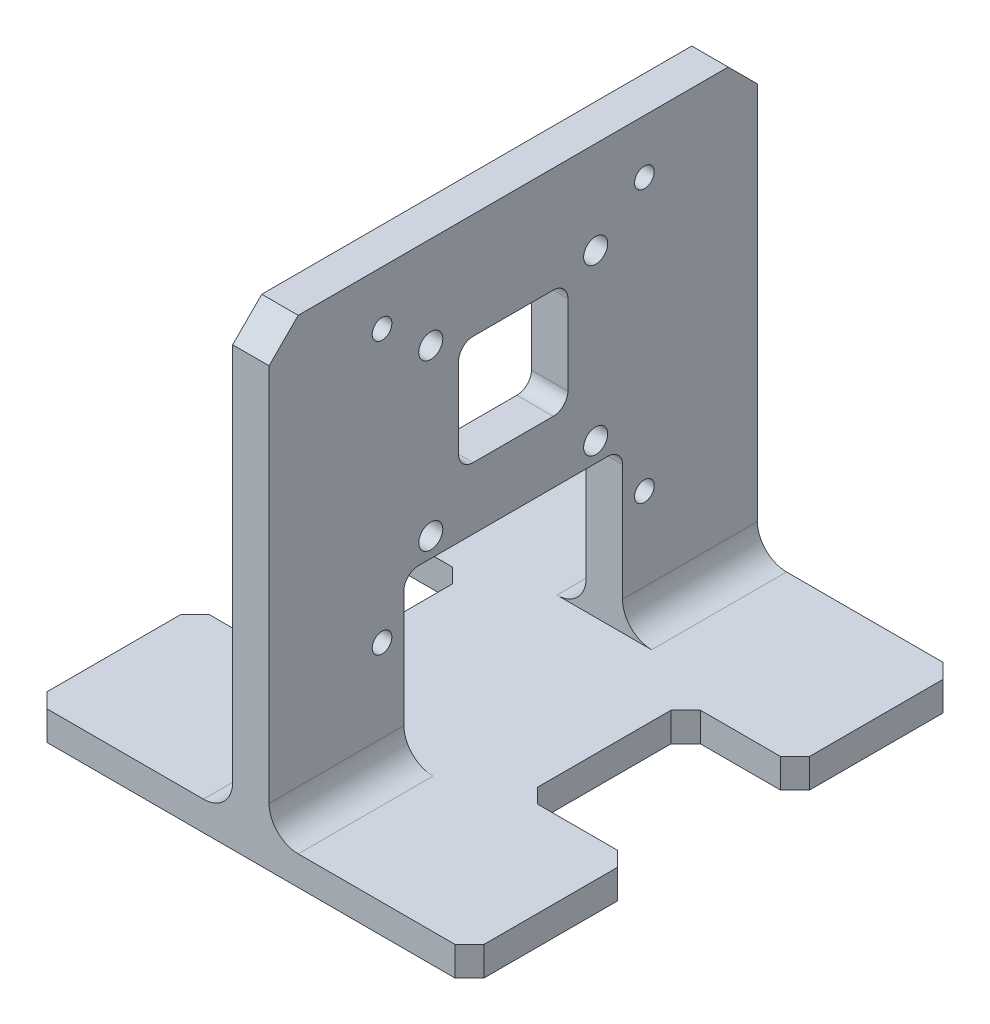
from build123d import *

# Parameters (mm, degrees)
BOSS_EXTRUDE1_DEPTH = 4
SKETCH2_W           = 5
SKETCH2_H           = 67
BOSS_EXTRUDE2_DEPTH = 60
SKETCH3_R           = 1.65
CUT_EXTRUDE1_DEPTH  = 33.5
SKETCH6_R           = 1.35
CUT_EXTRUDE3_DEPTH  = 33.5
SKETCH8_W           = 15
SKETCH8_H           = 15
CUT_EXTRUDE4_DEPTH  = 33.5
SKETCH9_W           = 30
SKETCH9_H           = 22
CUT_EXTRUDE5_DEPTH  = 33.5
FILLET1_R           = 2
FILLET2_R           = 2
CHAMFER1_SIZE       = 2
CHAMFER2_SIZE       = 2
CHAMFER3_SIZE       = 4
FILLET4_R           = 4


with BuildPart() as part:
    # Sketch1 → Boss-Extrude1 (new body)
    with BuildSketch(Plane(origin=(0, 0, 0), x_dir=(1, 0, 0), z_dir=(0, 1, 0))):
        Polygon((-30, 33.5), (30, 33.5), (30, 11.166666667), (15, 11.166666667), (15, -11.166666667), (30, -11.166666667), (30, -33.5), (-30, -33.5), (-30, -11.166666667), (-15, -11.166666667), (-15, 11.166666667), (-30, 11.166666667), align=None)
    extrude(amount=BOSS_EXTRUDE1_DEPTH)

    # Sketch2 → Boss-Extrude2 (add)
    with BuildSketch(Plane(origin=(0, 4, 0), x_dir=(1, 0, 0), z_dir=(0, 1, 0))):
        Rectangle(SKETCH2_W, SKETCH2_H)
    extrude(amount=BOSS_EXTRUDE2_DEPTH)

    # Sketch3 → Cut-Extrude1 (cut, through all)
    with BuildSketch(Plane.ZY.offset(2.5)):
        with Locations((-11.315, 51.315)):
            Circle(SKETCH3_R)
        with Locations((-11.315, 28.685)):
            Circle(SKETCH3_R)
        with Locations((11.315, 28.685)):
            Circle(SKETCH3_R)
        with Locations((11.315, 51.315)):
            Circle(SKETCH3_R)
    extrude(amount=-CUT_EXTRUDE1_DEPTH, mode=Mode.SUBTRACT)

    # Sketch6 → Cut-Extrude3 (cut, through all)
    with BuildSketch(Plane.ZY.offset(2.5)):
        with Locations((-18, 56.64)):
            Circle(SKETCH6_R)
        with Locations((18, 56.64)):
            Circle(SKETCH6_R)
        with Locations((18, 19.36)):
            Circle(SKETCH6_R)
        with Locations((-18, 19.36)):
            Circle(SKETCH6_R)
    extrude(amount=-CUT_EXTRUDE3_DEPTH, mode=Mode.SUBTRACT)

    # Sketch8 → Cut-Extrude4 (cut, through all)
    with BuildSketch(Plane(origin=(2.5, 0, 0), x_dir=(0, 0, -1), z_dir=(1, 0, 0))):
        with Locations((0, 42)):
            Rectangle(SKETCH8_W, SKETCH8_H)
    extrude(amount=-CUT_EXTRUDE4_DEPTH, mode=Mode.SUBTRACT)

    # Sketch9 → Cut-Extrude5 (cut, through all)
    with BuildSketch(Plane(origin=(2.5, 0, 0), x_dir=(0, 0, -1), z_dir=(1, 0, 0))):
        with Locations((0, 15)):
            Rectangle(SKETCH9_W, SKETCH9_H)
    extrude(amount=-CUT_EXTRUDE5_DEPTH, mode=Mode.SUBTRACT)

    # Fillet1
    fillet1_edges = [part.edges().sort_by_distance(p)[0] for p in [
        (0, 26, -15),
        (0, 26, 15),
    ]]
    fillet(fillet1_edges, radius=FILLET1_R)

    # Fillet2
    fillet2_edges = [part.edges().sort_by_distance(p)[0] for p in [
        (0, 49.5, -7.5),
        (0, 34.5, -7.5),
        (0, 34.5, 7.5),
        (0, 49.5, 7.5),
    ]]
    fillet(fillet2_edges, radius=FILLET2_R)

    # Chamfer1
    chamfer1_edges = [part.edges().sort_by_distance(p)[0] for p in [
        (30, 2, -11.166666667),
        (30, 2, 11.166666667),
        (30, 2, 33.5),
        (-30, 2, 33.5),
        (-30, 2, 11.166666667),
        (-30, 2, -11.166666667),
        (-30, 2, -33.5),
        (30, 2, -33.5),
    ]]
    chamfer(chamfer1_edges, length=CHAMFER1_SIZE)

    # Chamfer2
    chamfer2_edges = [part.edges().sort_by_distance(p)[0] for p in [
        (15, 2, -11.166666667),
        (15, 2, 11.166666667),
        (-15, 2, 11.166666667),
        (-15, 2, -11.166666667),
    ]]
    chamfer(chamfer2_edges, length=CHAMFER2_SIZE)

    # Chamfer3
    chamfer3_edges = [part.edges().sort_by_distance(p)[0] for p in [
        (0, 64, -33.5),
        (0, 64, 33.5),
    ]]
    chamfer(chamfer3_edges, length=CHAMFER3_SIZE)

    # Fillet4
    fillet4_edges = [part.edges().sort_by_distance(p)[0] for p in [
        (-2.5, 4, 24.25),
        (2.5, 4, -24.25),
        (2.5, 4, 24.25),
        (-2.5, 4, -24.25),
    ]]
    fillet(fillet4_edges, radius=FILLET4_R)


solid = part.part
